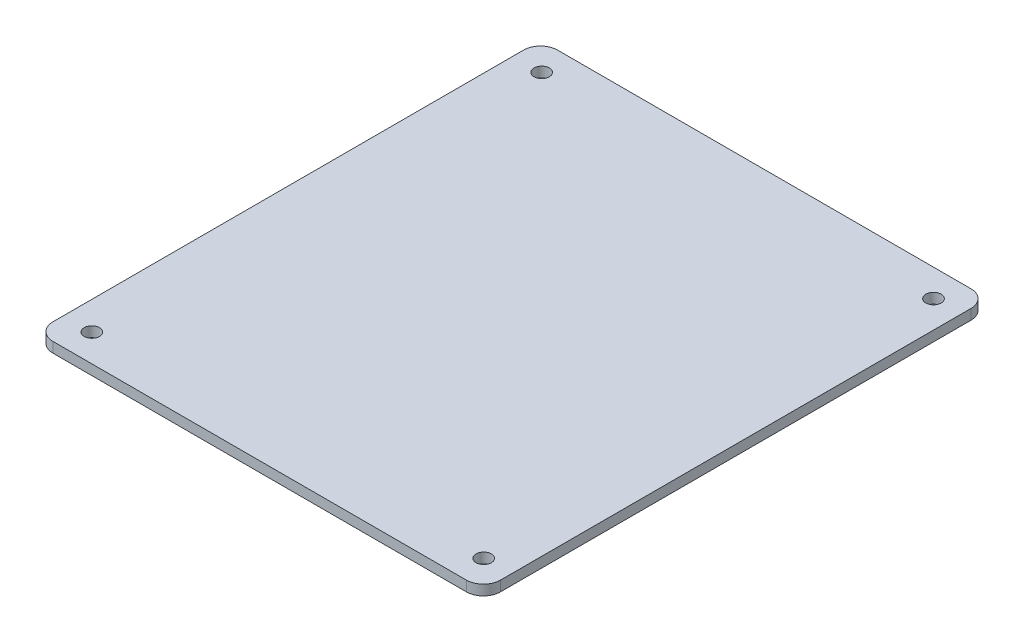
from build123d import *

# Parameters (mm, degrees)
SKETCH1_W           = 131.318
SKETCH1_H           = 148.082
BOSS_EXTRUDE1_DEPTH = 3
SKETCH2_R           = 2.25
CUT_EXTRUDE1_DEPTH  = 4
FILLET1_R           = 5


with BuildPart() as part:
    # Sketch1 → Boss-Extrude1 (new body)
    with BuildSketch(Plane(origin=(0, 0, 0), x_dir=(1, 0, 0), z_dir=(0, 1, 0))):
        with Locations((0.406931424, 0.203465712)):
            Rectangle(SKETCH1_W, SKETCH1_H)
    extrude(amount=BOSS_EXTRUDE1_DEPTH)

    # Sketch2 → Cut-Extrude1 (cut, through all)
    with BuildSketch(Plane(origin=(0, 3, 0), x_dir=(1, 0, 0), z_dir=(0, 1, 0))):
        with Locations((-56.934068576, -65.755534288)):
            Circle(SKETCH2_R)
        with Locations((-56.934068576, 66.244465712)):
            Circle(SKETCH2_R)
        with Locations((58.065931424, 66.244465712)):
            Circle(SKETCH2_R)
        with Locations((58.065931424, -65.755534288)):
            Circle(SKETCH2_R)
    extrude(amount=-CUT_EXTRUDE1_DEPTH, mode=Mode.SUBTRACT)

    # Fillet1
    fillet1_edges = [part.edges().sort_by_distance(p)[0] for p in [
        (-65.252068576, 1.5, 73.837534288),
        (-65.252068576, 1.5, -74.244465712),
        (66.065931424, 1.5, -74.244465712),
        (66.065931424, 1.5, 73.837534288),
    ]]
    fillet(fillet1_edges, radius=FILLET1_R)


solid = part.part
